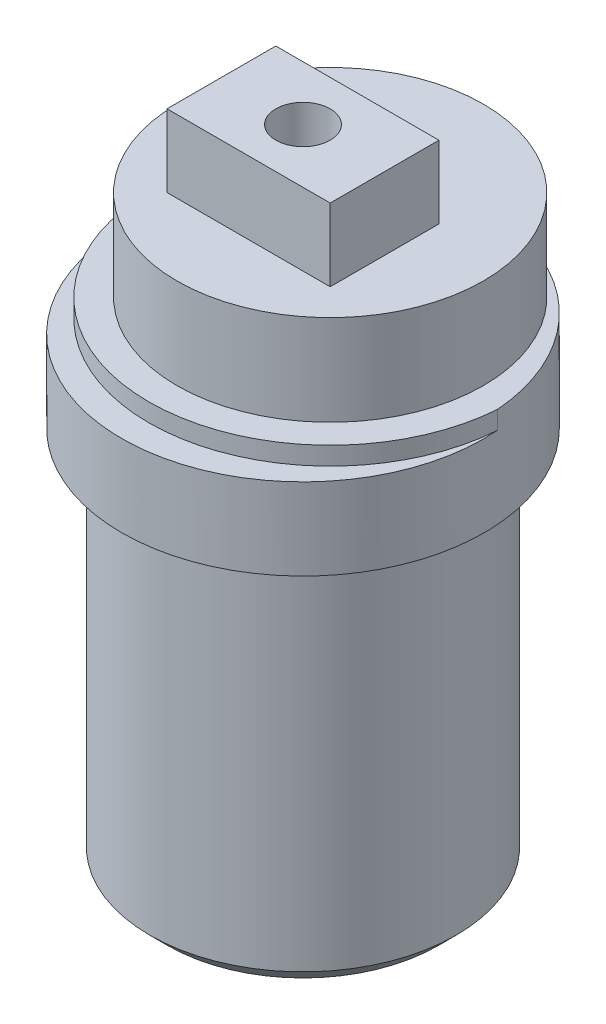
from build123d import *

# Parameters (mm, degrees)
SKETCH1_R           = 8.45
BOSS_EXTRUDE1_DEPTH = 21
SKETCH2_R           = 10
BOSS_EXTRUDE2_DEPTH = 4.5
SKETCH3_R           = 8.45
BOSS_EXTRUDE3_DEPTH = 6
SKETCH4_R           = 8.45
BOSS_EXTRUDE4_DEPTH = 1
SKETCH5_W           = 9
SKETCH5_H           = 6
BOSS_EXTRUDE5_DEPTH = 4
SKETCH6_R           = 1.5
CUT_EXTRUDE1_DEPTH  = 8
CUT_EXTRUDE3_DEPTH  = 30
CHAMFER1_SIZE       = 1


with BuildPart() as part:
    # Sketch1 → Boss-Extrude1 (new body)
    with BuildSketch(Plane(origin=(0, 0, 0), x_dir=(1, 0, 0), z_dir=(0, 1, 0))):
        Circle(SKETCH1_R)
    extrude(amount=BOSS_EXTRUDE1_DEPTH)

    # Sketch2 → Boss-Extrude2 (add)
    with BuildSketch(Plane(origin=(0, 21, 0), x_dir=(1, 0, 0), z_dir=(0, 1, 0))):
        Circle(SKETCH2_R)
    extrude(amount=BOSS_EXTRUDE2_DEPTH)

    # Sketch3 → Boss-Extrude3 (add)
    with BuildSketch(Plane(origin=(0, 25.5, 0), x_dir=(1, 0, 0), z_dir=(0, 1, 0))):
        with Locations((0, 1.5)):
            Circle(SKETCH3_R)
    extrude(amount=BOSS_EXTRUDE3_DEPTH)

    # Sketch4 → Boss-Extrude4 (add)
    with BuildSketch(Plane(origin=(0, 25.5, 0), x_dir=(1, 0, 0), z_dir=(0, 1, 0))):
        with BuildLine():
            ThreePointArc((9.971835338, 0.75), (0, 10), (-9.971835338, 0.75))
            ThreePointArc((-9.971835338, 0.75), (0, -8.5), (9.971835338, 0.75))
        make_face()
        with Locations((0, 1.5)):
            Circle(SKETCH4_R, mode=Mode.SUBTRACT)
    extrude(amount=BOSS_EXTRUDE4_DEPTH)

    # Sketch5 → Boss-Extrude5 (add)
    with BuildSketch(Plane(origin=(0, 31.5, 0), x_dir=(1, 0, 0), z_dir=(0, 1, 0))):
        Rectangle(SKETCH5_W, SKETCH5_H)
    extrude(amount=BOSS_EXTRUDE5_DEPTH)

    # Sketch6 → Cut-Extrude1 (cut)
    with BuildSketch(Plane(origin=(0, 35.5, 0), x_dir=(1, 0, 0), z_dir=(0, 1, 0))):
        Circle(SKETCH6_R)
    extrude(amount=-CUT_EXTRUDE1_DEPTH, mode=Mode.SUBTRACT)

    # Sketch8 → Cut-Extrude3 (cut)
    with BuildSketch(Plane.XZ):
        with BuildLine():
            ThreePointArc((1.943316155, 2.925914586), (1.699048653, 3.074197053), (1.443536153, 3.202133229))
            add(Edge.make_bspline(
                [(1.443536153, 3.202133229), (1.444031707, 3.223830116), (1.44398849, 3.268683064), (1.440824568, 3.338668541), (1.434115766, 3.41398948), (1.423301357, 3.49507766), (1.407896176, 3.581722393), (1.387267561, 3.673599968), (1.361458781, 3.770678005), (1.325563984, 3.878324655), (1.299816317, 3.963754312), (1.269287176, 4.016921178), (1.254329579, 4.036617994), (1.237294912, 4.054558617), (1.218164406, 4.070191292), (1.19356956, 4.087238463), (1.163917734, 4.095781007), (1.134023041, 4.094432002), (1.109507694, 4.09137348), (1.085539043, 4.08524571), (1.062394745, 4.076525861), (1.008258504, 4.04775067), (0.941006014, 3.989113898), (0.85334155, 3.917064057), (0.779840002, 3.848596833), (0.713491437, 3.781776952), (0.65434972, 3.71660881), (0.602051386, 3.653703098), (0.556297725, 3.593496334), (0.516384238, 3.535921245), (0.492484438, 3.497966161), (0.481360595, 3.479331232)],
                knots=[0.027203348, 0.027203348, 0.027203348, 0.027203348, 0.05931822, 0.093555562, 0.130845058, 0.171186709, 0.214580515, 0.261026475, 0.31052459, 0.363074859, 0.429245309, 0.441417135, 0.453588962, 0.465760788, 0.477932615, 0.490104441, 0.509895559, 0.522067385, 0.534239212, 0.546411038, 0.558582865, 0.570754691, 0.636925141, 0.68947541, 0.738973525, 0.785419485, 0.828813291, 0.869154942, 0.906444438, 0.94068178, 0.972796652, 0.972796652, 0.972796652, 0.972796652], degree=3, weights=[1, 1, 1, 1, 1, 1, 1, 1, 1, 1, 1, 1, 1, 1, 1, 1, 1, 1, 1, 1, 1, 1, 1, 1, 1, 1, 1, 1, 1, 1, 1, 1]))
            ThreePointArc((0.481360595, 3.479331232), (0.196945829, 3.506945421), (-0.088772405, 3.511349214))
            add(Edge.make_bspline(
                [(-0.088772405, 3.511349214), (-0.097739853, 3.531112446), (-0.117239755, 3.571504805), (-0.15045591, 3.633186767), (-0.189180863, 3.698137748), (-0.234107151, 3.766503478), (-0.28558048, 3.837883627), (-0.344030407, 3.911712041), (-0.409403895, 3.98797832), (-0.48845012, 4.069390432), (-0.548714506, 4.135188398), (-0.59928855, 4.169843992), (-0.621311008, 4.181100352), (-0.644442858, 4.18987323), (-0.668461611, 4.195657368), (-0.698017292, 4.200345035), (-0.728439135, 4.195176156), (-0.754788011, 4.180989923), (-0.775548532, 4.16759748), (-0.794484801, 4.151676941), (-0.811553693, 4.133778694), (-0.847843672, 4.084364309), (-0.882994531, 4.00235464), (-0.930716229, 3.899403792), (-0.96723202, 3.805825828), (-0.998017952, 3.716835632), (-1.023027401, 3.632460536), (-1.042852806, 3.55309305), (-1.057952694, 3.478996861), (-1.068932609, 3.409805685), (-1.073997491, 3.365239602), (-1.075934334, 3.343623656)],
                knots=[0.027203348, 0.027203348, 0.027203348, 0.027203348, 0.05931822, 0.093555562, 0.130845058, 0.171186709, 0.214580515, 0.261026475, 0.31052459, 0.363074859, 0.429245309, 0.441417135, 0.453588962, 0.465760788, 0.477932615, 0.490104441, 0.509895559, 0.522067385, 0.534239212, 0.546411038, 0.558582865, 0.570754691, 0.636925141, 0.68947541, 0.738973525, 0.785419485, 0.828813291, 0.869154942, 0.906444438, 0.94068178, 0.972796652, 0.972796652, 0.972796652, 0.972796652], degree=3, weights=[1, 1, 1, 1, 1, 1, 1, 1, 1, 1, 1, 1, 1, 1, 1, 1, 1, 1, 1, 1, 1, 1, 1, 1, 1, 1, 1, 1, 1, 1, 1, 1]))
            ThreePointArc((-1.075934334, 3.343623656), (-1.344164531, 3.245100238), (-1.603498499, 3.125099423))
            add(Edge.make_bspline(
                [(-1.603498499, 3.125099423), (-1.620152836, 3.13901465), (-1.655247228, 3.166946218), (-1.71193675, 3.208107795), (-1.775007901, 3.24982448), (-1.845147867, 3.291927088), (-1.922494421, 3.33390494), (-2.007188933, 3.37506157), (-2.099179109, 3.415410619), (-2.205720688, 3.454463526), (-2.288565692, 3.487597708), (-2.349167829, 3.496878064), (-2.37389333, 3.497464507), (-2.398540815, 3.495332064), (-2.422690608, 3.490122045), (-2.451353259, 3.481521758), (-2.476519699, 3.463665216), (-2.49410404, 3.439451513), (-2.506997861, 3.418377686), (-2.517151187, 3.395817637), (-2.524763968, 3.372285959), (-2.536020012, 3.312019505), (-2.532107179, 3.22287996), (-2.530434245, 3.109418782), (-2.522731879, 3.009264342), (-2.511857646, 2.915729431), (-2.497781398, 2.828858903), (-2.48120721, 2.748749348), (-2.462662608, 2.675439393), (-2.442534243, 2.608336291), (-2.427761045, 2.565986067), (-2.420127273, 2.545670408)],
                knots=[0.027203348, 0.027203348, 0.027203348, 0.027203348, 0.05931822, 0.093555562, 0.130845058, 0.171186709, 0.214580515, 0.261026475, 0.31052459, 0.363074859, 0.429245309, 0.441417135, 0.453588962, 0.465760788, 0.477932615, 0.490104441, 0.509895559, 0.522067385, 0.534239212, 0.546411038, 0.558582865, 0.570754691, 0.636925141, 0.68947541, 0.738973525, 0.785419485, 0.828813291, 0.869154942, 0.906444438, 0.94068178, 0.972796652, 0.972796652, 0.972796652, 0.972796652], degree=3, weights=[1, 1, 1, 1, 1, 1, 1, 1, 1, 1, 1, 1, 1, 1, 1, 1, 1, 1, 1, 1, 1, 1, 1, 1, 1, 1, 1, 1, 1, 1, 1, 1]))
            ThreePointArc((-2.420127273, 2.545670408), (-2.619046621, 2.340523155), (-2.800632051, 2.119885365))
            add(Edge.make_bspline(
                [(-2.800632051, 2.119885365), (-2.82167468, 2.125196505), (-2.865412688, 2.135135092), (-2.934347522, 2.14762373), (-3.009272856, 2.157843617), (-3.090734419, 2.165344166), (-3.178634763, 2.169605492), (-3.272799074, 2.169938763), (-3.373186155, 2.166378958), (-3.486121223, 2.155337752), (-3.575138375, 2.149245519), (-3.63376561, 2.131312549), (-3.656296964, 2.121112923), (-3.677578348, 2.108497515), (-3.697076017, 2.093325248), (-3.719168648, 2.073140399), (-3.734095165, 2.046132902), (-3.739432177, 2.016687549), (-3.741905517, 1.992106268), (-3.741264909, 1.967375003), (-3.737913776, 1.942870632), (-3.721906486, 1.883688618), (-3.679704947, 1.805074378), (-3.628968725, 1.703575248), (-3.57857375, 1.616681147), (-3.528193127, 1.537127257), (-3.477819157, 1.46496707), (-3.428128096, 1.399982127), (-3.379611989, 1.341978341), (-3.332362014, 1.290253905), (-3.300676749, 1.258507522), (-3.284984324, 1.243515915)],
                knots=[0.027203348, 0.027203348, 0.027203348, 0.027203348, 0.05931822, 0.093555562, 0.130845058, 0.171186709, 0.214580515, 0.261026475, 0.31052459, 0.363074859, 0.429245309, 0.441417135, 0.453588962, 0.465760788, 0.477932615, 0.490104441, 0.509895559, 0.522067385, 0.534239212, 0.546411038, 0.558582865, 0.570754691, 0.636925141, 0.68947541, 0.738973525, 0.785419485, 0.828813291, 0.869154942, 0.906444438, 0.94068178, 0.972796652, 0.972796652, 0.972796652, 0.972796652], degree=3, weights=[1, 1, 1, 1, 1, 1, 1, 1, 1, 1, 1, 1, 1, 1, 1, 1, 1, 1, 1, 1, 1, 1, 1, 1, 1, 1, 1, 1, 1, 1, 1, 1]))
            ThreePointArc((-3.284984324, 1.243515915), (-3.375194407, 0.972376756), (-3.443066077, 0.694802011))
            add(Edge.make_bspline(
                [(-3.443066077, 0.694802011), (-3.464329248, 0.690457129), (-3.508048023, 0.680434275), (-3.575574779, 0.661776446), (-3.647514416, 0.638475362), (-3.724163113, 0.609888276), (-3.805207507, 0.575589068), (-3.890191221, 0.535032971), (-3.979092314, 0.488269375), (-4.076052694, 0.429320903), (-4.153611056, 0.385208897), (-4.198651546, 0.343614445), (-4.214526143, 0.324648911), (-4.228226387, 0.304049175), (-4.23921018, 0.281919713), (-4.250357075, 0.254148159), (-4.252087287, 0.223338872), (-4.244119909, 0.194493883), (-4.235682894, 0.171273772), (-4.224375232, 0.149269622), (-4.210723917, 0.128645949), (-4.170623734, 0.082270099), (-4.098492021, 0.029751678), (-4.008741442, -0.039682257), (-3.925635201, -0.096105576), (-3.845726689, -0.145921822), (-3.769032179, -0.189079457), (-3.69606617, -0.226068725), (-3.627187768, -0.25727798), (-3.56217462, -0.283379091), (-3.519852944, -0.298233872), (-3.499209943, -0.304932155)],
                knots=[0.027203348, 0.027203348, 0.027203348, 0.027203348, 0.05931822, 0.093555562, 0.130845058, 0.171186709, 0.214580515, 0.261026475, 0.31052459, 0.363074859, 0.429245309, 0.441417135, 0.453588962, 0.465760788, 0.477932615, 0.490104441, 0.509895559, 0.522067385, 0.534239212, 0.546411038, 0.558582865, 0.570754691, 0.636925141, 0.68947541, 0.738973525, 0.785419485, 0.828813291, 0.869154942, 0.906444438, 0.94068178, 0.972796652, 0.972796652, 0.972796652, 0.972796652], degree=3, weights=[1, 1, 1, 1, 1, 1, 1, 1, 1, 1, 1, 1, 1, 1, 1, 1, 1, 1, 1, 1, 1, 1, 1, 1, 1, 1, 1, 1, 1, 1, 1, 1]))
            ThreePointArc((-3.499209943, -0.304932155), (-3.462843547, -0.588360784), (-3.40355864, -0.867895402))
            add(Edge.make_bspline(
                [(-3.40355864, -0.867895402), (-3.420830922, -0.88103575), (-3.455871423, -0.909034894), (-3.5086156, -0.955143779), (-3.563321011, -1.007350769), (-3.61997563, -1.066363467), (-3.678112237, -1.132429831), (-3.737083286, -1.205842663), (-3.79689044, -1.286547945), (-3.858671941, -1.381728216), (-3.909410127, -1.455123072), (-3.93194305, -1.512140715), (-3.938016731, -1.5361158), (-3.941422334, -1.560619834), (-3.941716776, -1.585323479), (-3.939710156, -1.615181241), (-3.927901374, -1.643690161), (-3.908207643, -1.666221682), (-3.890531326, -1.683481595), (-3.870796232, -1.698400439), (-3.849548546, -1.711058643), (-3.793297802, -1.735443022), (-3.705522485, -1.751463707), (-3.594533753, -1.775080204), (-3.495176456, -1.789857412), (-3.401566916, -1.800069294), (-3.313742153, -1.805676479), (-3.231953009, -1.807343893), (-3.156354525, -1.805577242), (-3.086454855, -1.800885382), (-3.041879094, -1.795906391), (-3.020374117, -1.792984673)],
                knots=[0.027203348, 0.027203348, 0.027203348, 0.027203348, 0.05931822, 0.093555562, 0.130845058, 0.171186709, 0.214580515, 0.261026475, 0.31052459, 0.363074859, 0.429245309, 0.441417135, 0.453588962, 0.465760788, 0.477932615, 0.490104441, 0.509895559, 0.522067385, 0.534239212, 0.546411038, 0.558582865, 0.570754691, 0.636925141, 0.68947541, 0.738973525, 0.785419485, 0.828813291, 0.869154942, 0.906444438, 0.94068178, 0.972796652, 0.972796652, 0.972796652, 0.972796652], degree=3, weights=[1, 1, 1, 1, 1, 1, 1, 1, 1, 1, 1, 1, 1, 1, 1, 1, 1, 1, 1, 1, 1, 1, 1, 1, 1, 1, 1, 1, 1, 1, 1, 1]))
            ThreePointArc((-3.020374117, -1.792984673), (-2.864634053, -2.032566256), (-2.689934673, -2.258695486))
            add(Edge.make_bspline(
                [(-2.689934673, -2.258695486), (-2.699795077, -2.278028694), (-2.719217105, -2.318458555), (-2.746732071, -2.382886065), (-2.773368179, -2.453658726), (-2.798807576, -2.531408848), (-2.822521729, -2.616157113), (-2.843800174, -2.707886368), (-2.862667848, -2.806548667), (-2.877033885, -2.919109116), (-2.890902577, -3.007250071), (-2.886465011, -3.06839786), (-2.881534809, -3.092633937), (-2.873971249, -3.116188945), (-2.863518022, -3.138573914), (-2.848755322, -3.164604188), (-2.825746421, -3.185166199), (-2.798226922, -3.196921608), (-2.774812315, -3.204802786), (-2.750558566, -3.209681463), (-2.725922874, -3.211867086), (-2.664662719, -3.209430369), (-2.578628776, -3.185780225), (-2.46838457, -3.158901747), (-2.372455148, -3.129106036), (-2.283685097, -3.097690966), (-2.202124854, -3.064637129), (-2.127711918, -3.030652437), (-2.060366558, -2.996259787), (-1.999424853, -2.961704237), (-1.961423784, -2.937877623), (-1.943316155, -2.925914586)],
                knots=[0.027203348, 0.027203348, 0.027203348, 0.027203348, 0.05931822, 0.093555562, 0.130845058, 0.171186709, 0.214580515, 0.261026475, 0.31052459, 0.363074859, 0.429245309, 0.441417135, 0.453588962, 0.465760788, 0.477932615, 0.490104441, 0.509895559, 0.522067385, 0.534239212, 0.546411038, 0.558582865, 0.570754691, 0.636925141, 0.68947541, 0.738973525, 0.785419485, 0.828813291, 0.869154942, 0.906444438, 0.94068178, 0.972796652, 0.972796652, 0.972796652, 0.972796652], degree=3, weights=[1, 1, 1, 1, 1, 1, 1, 1, 1, 1, 1, 1, 1, 1, 1, 1, 1, 1, 1, 1, 1, 1, 1, 1, 1, 1, 1, 1, 1, 1, 1, 1]))
            ThreePointArc((-1.943316155, -2.925914586), (-1.699048653, -3.074197053), (-1.443536153, -3.202133229))
            add(Edge.make_bspline(
                [(-1.443536153, -3.202133229), (-1.444031707, -3.223830116), (-1.44398849, -3.268683064), (-1.440824568, -3.338668541), (-1.434115766, -3.41398948), (-1.423301357, -3.49507766), (-1.407896176, -3.581722393), (-1.387267561, -3.673599968), (-1.361458781, -3.770678005), (-1.325563984, -3.878324655), (-1.299816317, -3.963754312), (-1.269287176, -4.016921178), (-1.254329579, -4.036617994), (-1.237294912, -4.054558617), (-1.218164406, -4.070191292), (-1.19356956, -4.087238463), (-1.163917734, -4.095781007), (-1.134023041, -4.094432002), (-1.109507694, -4.09137348), (-1.085539043, -4.08524571), (-1.062394745, -4.076525861), (-1.008258504, -4.04775067), (-0.941006014, -3.989113898), (-0.85334155, -3.917064057), (-0.779840002, -3.848596833), (-0.713491437, -3.781776952), (-0.65434972, -3.71660881), (-0.602051386, -3.653703098), (-0.556297725, -3.593496334), (-0.516384238, -3.535921245), (-0.492484438, -3.497966161), (-0.481360595, -3.479331232)],
                knots=[0.027203348, 0.027203348, 0.027203348, 0.027203348, 0.05931822, 0.093555562, 0.130845058, 0.171186709, 0.214580515, 0.261026475, 0.31052459, 0.363074859, 0.429245309, 0.441417135, 0.453588962, 0.465760788, 0.477932615, 0.490104441, 0.509895559, 0.522067385, 0.534239212, 0.546411038, 0.558582865, 0.570754691, 0.636925141, 0.68947541, 0.738973525, 0.785419485, 0.828813291, 0.869154942, 0.906444438, 0.94068178, 0.972796652, 0.972796652, 0.972796652, 0.972796652], degree=3, weights=[1, 1, 1, 1, 1, 1, 1, 1, 1, 1, 1, 1, 1, 1, 1, 1, 1, 1, 1, 1, 1, 1, 1, 1, 1, 1, 1, 1, 1, 1, 1, 1]))
            ThreePointArc((-0.481360595, -3.479331232), (-0.196945829, -3.506945421), (0.088772405, -3.511349214))
            add(Edge.make_bspline(
                [(0.088772405, -3.511349214), (0.097739853, -3.531112446), (0.117239755, -3.571504805), (0.15045591, -3.633186767), (0.189180863, -3.698137748), (0.234107151, -3.766503478), (0.28558048, -3.837883627), (0.344030407, -3.911712041), (0.409403895, -3.98797832), (0.48845012, -4.069390432), (0.548714506, -4.135188398), (0.59928855, -4.169843992), (0.621311008, -4.181100352), (0.644442858, -4.18987323), (0.668461611, -4.195657368), (0.698017292, -4.200345035), (0.728439135, -4.195176156), (0.754788011, -4.180989923), (0.775548532, -4.16759748), (0.794484801, -4.151676941), (0.811553693, -4.133778694), (0.847843672, -4.084364309), (0.882994531, -4.00235464), (0.930716229, -3.899403792), (0.96723202, -3.805825828), (0.998017952, -3.716835632), (1.023027401, -3.632460536), (1.042852806, -3.55309305), (1.057952694, -3.478996861), (1.068932609, -3.409805685), (1.073997491, -3.365239602), (1.075934334, -3.343623656)],
                knots=[0.027203348, 0.027203348, 0.027203348, 0.027203348, 0.05931822, 0.093555562, 0.130845058, 0.171186709, 0.214580515, 0.261026475, 0.31052459, 0.363074859, 0.429245309, 0.441417135, 0.453588962, 0.465760788, 0.477932615, 0.490104441, 0.509895559, 0.522067385, 0.534239212, 0.546411038, 0.558582865, 0.570754691, 0.636925141, 0.68947541, 0.738973525, 0.785419485, 0.828813291, 0.869154942, 0.906444438, 0.94068178, 0.972796652, 0.972796652, 0.972796652, 0.972796652], degree=3, weights=[1, 1, 1, 1, 1, 1, 1, 1, 1, 1, 1, 1, 1, 1, 1, 1, 1, 1, 1, 1, 1, 1, 1, 1, 1, 1, 1, 1, 1, 1, 1, 1]))
            ThreePointArc((1.075934334, -3.343623656), (1.344164531, -3.245100238), (1.603498499, -3.125099423))
            add(Edge.make_bspline(
                [(1.603498499, -3.125099423), (1.620152836, -3.13901465), (1.655247228, -3.166946218), (1.71193675, -3.208107795), (1.775007901, -3.24982448), (1.845147867, -3.291927088), (1.922494421, -3.33390494), (2.007188933, -3.37506157), (2.099179109, -3.415410619), (2.205720688, -3.454463526), (2.288565692, -3.487597708), (2.349167829, -3.496878064), (2.37389333, -3.497464507), (2.398540815, -3.495332064), (2.422690608, -3.490122045), (2.451353259, -3.481521758), (2.476519699, -3.463665216), (2.49410404, -3.439451513), (2.506997861, -3.418377686), (2.517151187, -3.395817637), (2.524763968, -3.372285959), (2.536020012, -3.312019505), (2.532107179, -3.22287996), (2.530434245, -3.109418782), (2.522731879, -3.009264342), (2.511857646, -2.915729431), (2.497781398, -2.828858903), (2.48120721, -2.748749348), (2.462662608, -2.675439393), (2.442534243, -2.608336291), (2.427761045, -2.565986067), (2.420127273, -2.545670408)],
                knots=[0.027203348, 0.027203348, 0.027203348, 0.027203348, 0.05931822, 0.093555562, 0.130845058, 0.171186709, 0.214580515, 0.261026475, 0.31052459, 0.363074859, 0.429245309, 0.441417135, 0.453588962, 0.465760788, 0.477932615, 0.490104441, 0.509895559, 0.522067385, 0.534239212, 0.546411038, 0.558582865, 0.570754691, 0.636925141, 0.68947541, 0.738973525, 0.785419485, 0.828813291, 0.869154942, 0.906444438, 0.94068178, 0.972796652, 0.972796652, 0.972796652, 0.972796652], degree=3, weights=[1, 1, 1, 1, 1, 1, 1, 1, 1, 1, 1, 1, 1, 1, 1, 1, 1, 1, 1, 1, 1, 1, 1, 1, 1, 1, 1, 1, 1, 1, 1, 1]))
            ThreePointArc((2.420127273, -2.545670408), (2.619046621, -2.340523155), (2.800632051, -2.119885365))
            add(Edge.make_bspline(
                [(2.800632051, -2.119885365), (2.82167468, -2.125196505), (2.865412688, -2.135135092), (2.934347522, -2.14762373), (3.009272856, -2.157843617), (3.090734419, -2.165344166), (3.178634763, -2.169605492), (3.272799074, -2.169938763), (3.373186155, -2.166378958), (3.486121223, -2.155337752), (3.575138375, -2.149245519), (3.63376561, -2.131312549), (3.656296964, -2.121112923), (3.677578348, -2.108497515), (3.697076017, -2.093325248), (3.719168648, -2.073140399), (3.734095165, -2.046132902), (3.739432177, -2.016687549), (3.741905517, -1.992106268), (3.741264909, -1.967375003), (3.737913776, -1.942870632), (3.721906486, -1.883688618), (3.679704947, -1.805074378), (3.628968725, -1.703575248), (3.57857375, -1.616681147), (3.528193127, -1.537127257), (3.477819157, -1.46496707), (3.428128096, -1.399982127), (3.379611989, -1.341978341), (3.332362014, -1.290253905), (3.300676749, -1.258507522), (3.284984324, -1.243515915)],
                knots=[0.027203348, 0.027203348, 0.027203348, 0.027203348, 0.05931822, 0.093555562, 0.130845058, 0.171186709, 0.214580515, 0.261026475, 0.31052459, 0.363074859, 0.429245309, 0.441417135, 0.453588962, 0.465760788, 0.477932615, 0.490104441, 0.509895559, 0.522067385, 0.534239212, 0.546411038, 0.558582865, 0.570754691, 0.636925141, 0.68947541, 0.738973525, 0.785419485, 0.828813291, 0.869154942, 0.906444438, 0.94068178, 0.972796652, 0.972796652, 0.972796652, 0.972796652], degree=3, weights=[1, 1, 1, 1, 1, 1, 1, 1, 1, 1, 1, 1, 1, 1, 1, 1, 1, 1, 1, 1, 1, 1, 1, 1, 1, 1, 1, 1, 1, 1, 1, 1]))
            ThreePointArc((3.284984324, -1.243515915), (3.375194407, -0.972376756), (3.443066077, -0.694802011))
            add(Edge.make_bspline(
                [(3.443066077, -0.694802011), (3.464329248, -0.690457129), (3.508048023, -0.680434275), (3.575574779, -0.661776446), (3.647514416, -0.638475362), (3.724163113, -0.609888276), (3.805207507, -0.575589068), (3.890191221, -0.535032971), (3.979092314, -0.488269375), (4.076052694, -0.429320903), (4.153611056, -0.385208897), (4.198651546, -0.343614445), (4.214526143, -0.324648911), (4.228226387, -0.304049175), (4.23921018, -0.281919713), (4.250357075, -0.254148159), (4.252087287, -0.223338872), (4.244119909, -0.194493883), (4.235682894, -0.171273772), (4.224375232, -0.149269622), (4.210723917, -0.128645949), (4.170623734, -0.082270099), (4.098492021, -0.029751678), (4.008741442, 0.039682257), (3.925635201, 0.096105576), (3.845726689, 0.145921822), (3.769032179, 0.189079457), (3.69606617, 0.226068725), (3.627187768, 0.25727798), (3.56217462, 0.283379091), (3.519852944, 0.298233872), (3.499209943, 0.304932155)],
                knots=[0.027203348, 0.027203348, 0.027203348, 0.027203348, 0.05931822, 0.093555562, 0.130845058, 0.171186709, 0.214580515, 0.261026475, 0.31052459, 0.363074859, 0.429245309, 0.441417135, 0.453588962, 0.465760788, 0.477932615, 0.490104441, 0.509895559, 0.522067385, 0.534239212, 0.546411038, 0.558582865, 0.570754691, 0.636925141, 0.68947541, 0.738973525, 0.785419485, 0.828813291, 0.869154942, 0.906444438, 0.94068178, 0.972796652, 0.972796652, 0.972796652, 0.972796652], degree=3, weights=[1, 1, 1, 1, 1, 1, 1, 1, 1, 1, 1, 1, 1, 1, 1, 1, 1, 1, 1, 1, 1, 1, 1, 1, 1, 1, 1, 1, 1, 1, 1, 1]))
            ThreePointArc((3.499209943, 0.304932155), (3.462843547, 0.588360784), (3.40355864, 0.867895402))
            add(Edge.make_bspline(
                [(3.40355864, 0.867895402), (3.420830922, 0.88103575), (3.455871423, 0.909034894), (3.5086156, 0.955143779), (3.563321011, 1.007350769), (3.61997563, 1.066363467), (3.678112237, 1.132429831), (3.737083286, 1.205842663), (3.79689044, 1.286547945), (3.858671941, 1.381728216), (3.909410127, 1.455123072), (3.93194305, 1.512140715), (3.938016731, 1.5361158), (3.941422334, 1.560619834), (3.941716776, 1.585323479), (3.939710156, 1.615181241), (3.927901374, 1.643690161), (3.908207643, 1.666221682), (3.890531326, 1.683481595), (3.870796232, 1.698400439), (3.849548546, 1.711058643), (3.793297802, 1.735443022), (3.705522485, 1.751463707), (3.594533753, 1.775080204), (3.495176456, 1.789857412), (3.401566916, 1.800069294), (3.313742153, 1.805676479), (3.231953009, 1.807343893), (3.156354525, 1.805577242), (3.086454855, 1.800885382), (3.041879094, 1.795906391), (3.020374117, 1.792984673)],
                knots=[0.027203348, 0.027203348, 0.027203348, 0.027203348, 0.05931822, 0.093555562, 0.130845058, 0.171186709, 0.214580515, 0.261026475, 0.31052459, 0.363074859, 0.429245309, 0.441417135, 0.453588962, 0.465760788, 0.477932615, 0.490104441, 0.509895559, 0.522067385, 0.534239212, 0.546411038, 0.558582865, 0.570754691, 0.636925141, 0.68947541, 0.738973525, 0.785419485, 0.828813291, 0.869154942, 0.906444438, 0.94068178, 0.972796652, 0.972796652, 0.972796652, 0.972796652], degree=3, weights=[1, 1, 1, 1, 1, 1, 1, 1, 1, 1, 1, 1, 1, 1, 1, 1, 1, 1, 1, 1, 1, 1, 1, 1, 1, 1, 1, 1, 1, 1, 1, 1]))
            ThreePointArc((3.020374117, 1.792984673), (2.864634053, 2.032566256), (2.689934673, 2.258695486))
            add(Edge.make_bspline(
                [(2.689934673, 2.258695486), (2.699795077, 2.278028694), (2.719217105, 2.318458555), (2.746732071, 2.382886065), (2.773368179, 2.453658726), (2.798807576, 2.531408848), (2.822521729, 2.616157113), (2.843800174, 2.707886368), (2.862667848, 2.806548667), (2.877033885, 2.919109116), (2.890902577, 3.007250071), (2.886465011, 3.06839786), (2.881534809, 3.092633937), (2.873971249, 3.116188945), (2.863518022, 3.138573914), (2.848755322, 3.164604188), (2.825746421, 3.185166199), (2.798226922, 3.196921608), (2.774812315, 3.204802786), (2.750558566, 3.209681463), (2.725922874, 3.211867086), (2.664662719, 3.209430369), (2.578628776, 3.185780225), (2.46838457, 3.158901747), (2.372455148, 3.129106036), (2.283685097, 3.097690966), (2.202124854, 3.064637129), (2.127711918, 3.030652437), (2.060366558, 2.996259787), (1.999424853, 2.961704237), (1.961423784, 2.937877623), (1.943316155, 2.925914586)],
                knots=[0.027203348, 0.027203348, 0.027203348, 0.027203348, 0.05931822, 0.093555562, 0.130845058, 0.171186709, 0.214580515, 0.261026475, 0.31052459, 0.363074859, 0.429245309, 0.441417135, 0.453588962, 0.465760788, 0.477932615, 0.490104441, 0.509895559, 0.522067385, 0.534239212, 0.546411038, 0.558582865, 0.570754691, 0.636925141, 0.68947541, 0.738973525, 0.785419485, 0.828813291, 0.869154942, 0.906444438, 0.94068178, 0.972796652, 0.972796652, 0.972796652, 0.972796652], degree=3, weights=[1, 1, 1, 1, 1, 1, 1, 1, 1, 1, 1, 1, 1, 1, 1, 1, 1, 1, 1, 1, 1, 1, 1, 1, 1, 1, 1, 1, 1, 1, 1, 1]))
        make_face()
    extrude(amount=-CUT_EXTRUDE3_DEPTH, mode=Mode.SUBTRACT)

    # Chamfer1
    chamfer1_edges = [part.edges().sort_by_distance(p)[0] for p in [
        (-8.45, 0, 0),
    ]]
    chamfer(chamfer1_edges, length=CHAMFER1_SIZE)


solid = part.part
